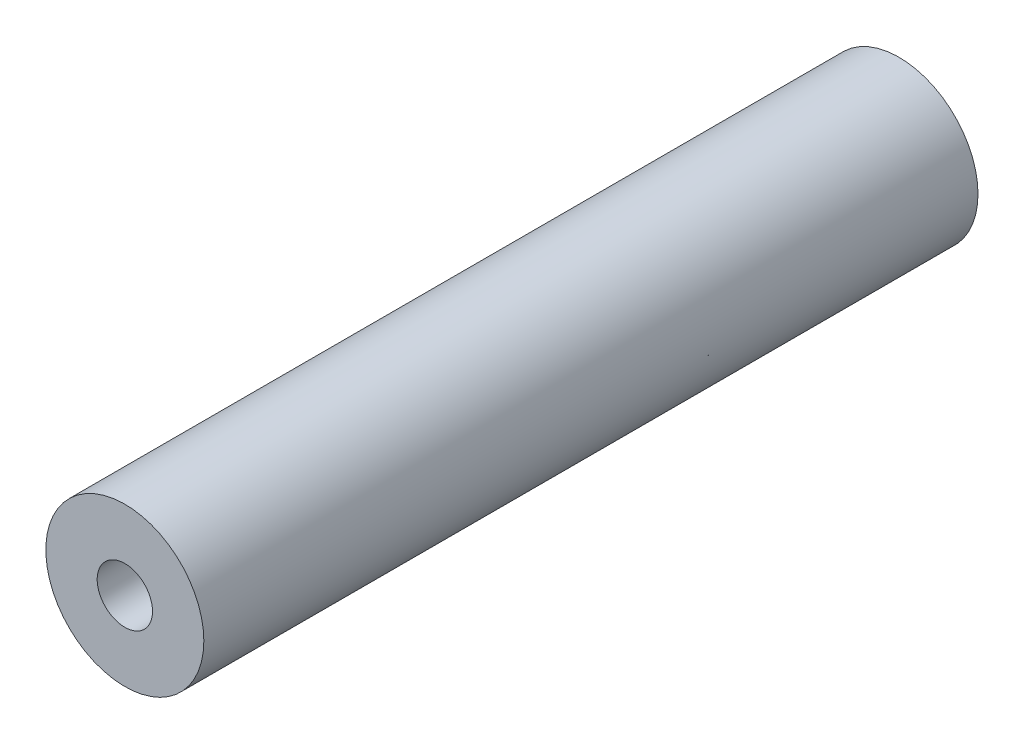
from build123d import *

# Parameters (mm, degrees)
SKETCH1_R           = 10
SKETCH1_R_2         = 7.5
BOSS_EXTRUDE1_DEPTH = 98
SKETCH2_R           = 7.5
BOSS_EXTRUDE2_DEPTH = 5
SKETCH3_R           = 3.5
CUT_EXTRUDE1_DEPTH  = 5
SKETCH4_R           = 7.5
BOSS_EXTRUDE4_DEPTH = 3
SKETCH5_R           = 6.688248189
CUT_EXTRUDE2_DEPTH  = 5


with BuildPart() as part:
    # Sketch1 → Boss-Extrude1 (new body)
    with BuildSketch(Plane.XY):
        Circle(SKETCH1_R)
        Circle(SKETCH1_R_2, mode=Mode.SUBTRACT)
    extrude(amount=BOSS_EXTRUDE1_DEPTH)

    # Sketch2 → Boss-Extrude2 (add)
    with BuildSketch(Plane.XY.offset(98)):
        Circle(SKETCH2_R)
    extrude(amount=-BOSS_EXTRUDE2_DEPTH)

    # Sketch3 → Cut-Extrude1 (cut)
    with BuildSketch(Plane.XY.offset(98)):
        Circle(SKETCH3_R)
    extrude(amount=-CUT_EXTRUDE1_DEPTH, mode=Mode.SUBTRACT)

    # Sketch4 → Boss-Extrude4 (add)
    with BuildSketch(Plane(origin=(0, 0, 0), x_dir=(-1, 0, 0), z_dir=(0, 0, -1))):
        Circle(SKETCH4_R)
    extrude(amount=-BOSS_EXTRUDE4_DEPTH)

    # Sketch5 → Cut-Extrude2 (cut)
    with BuildSketch(Plane(origin=(0, 0, 0), x_dir=(-1, 0, 0), z_dir=(0, 0, -1))):
        Circle(SKETCH5_R)
    extrude(amount=-CUT_EXTRUDE2_DEPTH, mode=Mode.SUBTRACT)


solid = part.part
